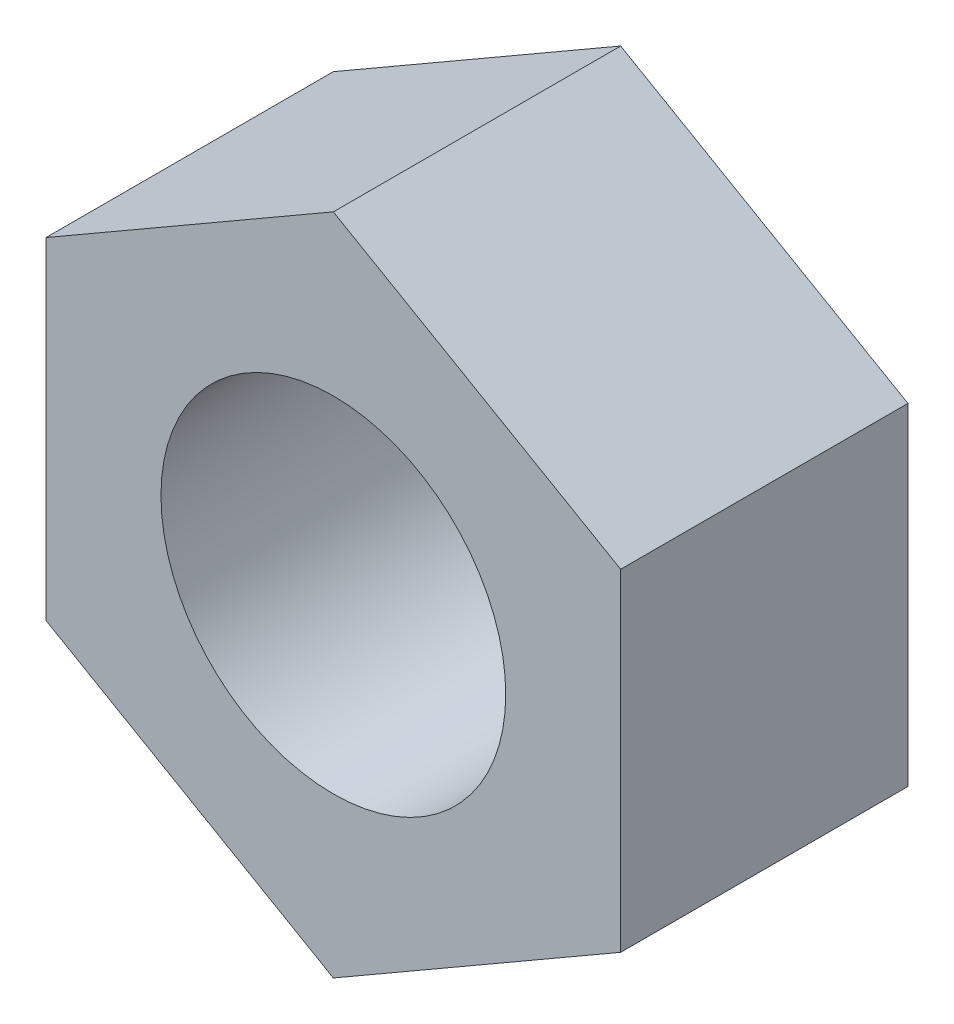
from build123d import *

# Parameters (mm, degrees)
EXTRUDE_1_DEPTH      = 5
M6X1_0_1_D           = 5
M6X1_0_1_DEPTH       = 17
M6X1_0_1_CBORE_D     = 6
M6X1_0_1_CBORE_DEPTH = 12
M6X1_0_1_TIP         = 1.502151548


with BuildPart() as part:
    # 草圖1 → 伸長1 (new body)
    with BuildSketch(Plane.XY):
        Polygon((0, -5.773502692), (5, -2.886751346), (5, 2.886751346), (0, 5.773502692), (-5, 2.886751346), (-5, -2.886751346), align=None)
    extrude(amount=EXTRUDE_1_DEPTH)

    # M6x1.0 螺紋孔1
    with Locations(Plane.XY.offset(5)):
        with Locations((0, 0)):
            CounterBoreHole(M6X1_0_1_D / 2, M6X1_0_1_CBORE_D / 2, M6X1_0_1_CBORE_DEPTH, depth=M6X1_0_1_DEPTH)
            with Locations((0, 0, -(M6X1_0_1_DEPTH + M6X1_0_1_TIP / 2))):  # 118° drill point
                Cone(0, M6X1_0_1_D / 2, M6X1_0_1_TIP, mode=Mode.SUBTRACT)


solid = part.part
